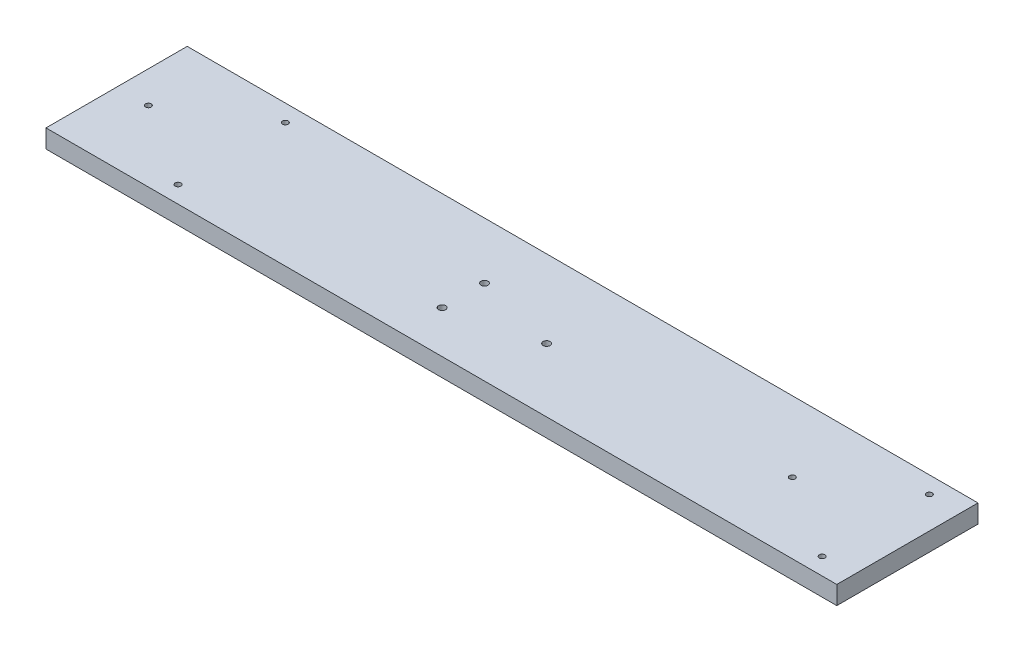
from build123d import *

# Parameters (mm, degrees)
SKETCH1_W           = 280
SKETCH1_H           = 50
BOSS_EXTRUDE1_DEPTH = 6.5
SKETCH2_R           = 1.25
CUT_EXTRUDE1_DEPTH  = 7.5
SKETCH3_R           = 1
CUT_EXTRUDE2_DEPTH  = 7.5


with BuildPart() as part:
    # Sketch1 → Boss-Extrude1 (new body)
    with BuildSketch(Plane(origin=(0, 0, 0), x_dir=(1, 0, 0), z_dir=(0, 1, 0))):
        with Locations((140, 25)):
            Rectangle(SKETCH1_W, SKETCH1_H)
    extrude(amount=BOSS_EXTRUDE1_DEPTH)

    # Sketch2 → Cut-Extrude1 (cut, through all)
    with BuildSketch(Plane(origin=(0, 0, 0), x_dir=(-1, 0, 0), z_dir=(0, -1, 0))):
        with Locations((-125.25, 30)):
            Circle(SKETCH2_R)
        with Locations((-125.25, 15)):
            Circle(SKETCH2_R)
        with Locations((-154.75, 22.5)):
            Circle(SKETCH2_R)
    extrude(amount=-CUT_EXTRUDE1_DEPTH, mode=Mode.SUBTRACT)

    # Sketch3 → Cut-Extrude2 (cut, through all)
    with BuildSketch(Plane.XZ):
        with Locations((268.798469713, -44)):
            Circle(SKETCH3_R)
        with Locations((268.798469713, -6)):
            Circle(SKETCH3_R)
        with Locations((239.25, -25)):
            Circle(SKETCH3_R)
        with Locations((11.25, -25)):
            Circle(SKETCH3_R)
        with Locations((40.75, -6)):
            Circle(SKETCH3_R)
        with Locations((40.75, -44)):
            Circle(SKETCH3_R)
    extrude(amount=-CUT_EXTRUDE2_DEPTH, mode=Mode.SUBTRACT)


solid = part.part
